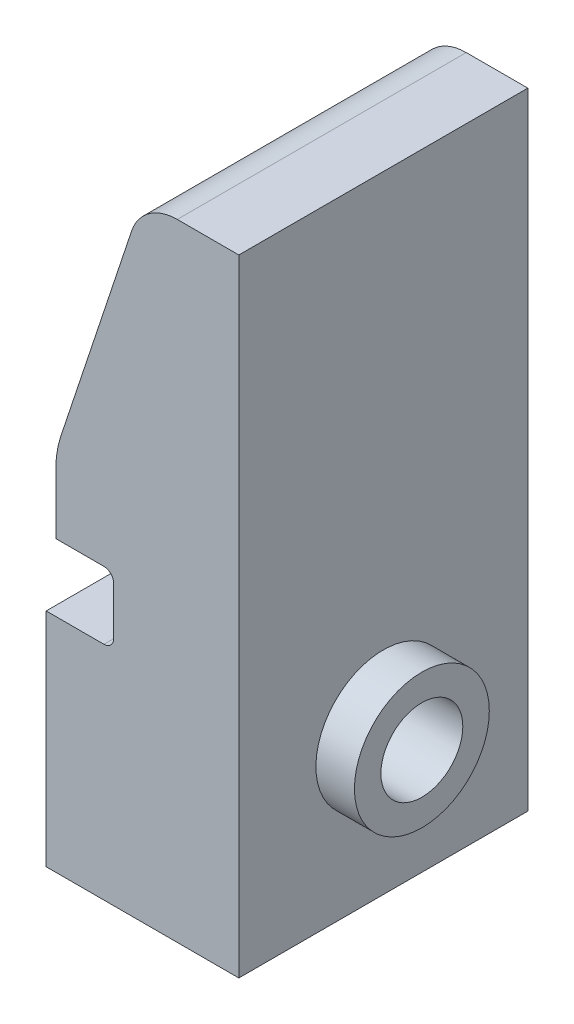
from build123d import *

# Parameters (mm, degrees)
EXTRUDE_1_DEPTH     = 30
SKETCH_2_R          = 4.25
CUT_EXTRUDE_1_DEPTH = 30
FILLET_1_R          = 10
FILLET_2_R          = 5
SKETCH_5_W          = 7
SKETCH_5_H          = 7
CUT_EXTRUDE_2_DEPTH = 20
FILLET_5_R          = 1
SKETCH_6_R          = 7
SKETCH_6_R_2        = 4.25
EXTRUDE_2_DEPTH     = 4


with BuildPart() as part:
    # 草图1 → 凸台-拉伸1 (new body)
    with BuildSketch(Plane.XY):
        Polygon((-4.331983806, 33.724696356), (-13.331983806, 6.619433198), (-13.331983806, -1.275303644), (-14.331983806, -1.275303644), (-14.331983806, -31.275303644), (5.668016194, -31.275303644), (5.668016194, 33.724696356), align=None)
    extrude(amount=EXTRUDE_1_DEPTH)

    # 草图2 → 切除-拉伸1 (cut)
    with BuildSketch(Plane.ZY.offset(14.331983806)):
        with Locations(Location((15, -16.275303644, 0), (0, 0, 270))):
            Circle(SKETCH_2_R)
    extrude(amount=-CUT_EXTRUDE_1_DEPTH, mode=Mode.SUBTRACT)

    # 圆角1
    fillet_1_edges = [part.edges().sort_by_distance(p)[0] for p in [
        (-13.331983806, 6.619433198, 15),
    ]]
    fillet(fillet_1_edges, radius=FILLET_1_R)

    # 圆角2
    fillet_2_edges = [part.edges().sort_by_distance(p)[0] for p in [
        (-4.331983806, 33.724696356, 15),
    ]]
    fillet(fillet_2_edges, radius=FILLET_2_R)

    # 草图5 → 切除-拉伸2 (cut)
    with BuildSketch(Plane.XY.offset(30)):
        with Locations((-10.831983806, -4.775303644)):
            Rectangle(SKETCH_5_W, SKETCH_5_H)
    extrude(amount=-CUT_EXTRUDE_2_DEPTH, mode=Mode.SUBTRACT)

    # 圆角5
    fillet_5_edges = [part.edges().sort_by_distance(p)[0] for p in [
        (-10.331983806, -1.275303644, 10),
        (-7.331983806, -4.775303644, 10),
        (-7.331983806, -1.275303644, 20),
        (-10.831983806, -8.275303644, 10),
        (-7.331983806, -8.275303644, 20),
    ]]
    fillet(fillet_5_edges, radius=FILLET_5_R)

    # 草图6 → 凸台-拉伸2 (add)
    with BuildSketch(Plane(origin=(5.668016194, 0, 0), x_dir=(0, 0, -1), z_dir=(1, 0, 0))):
        with Locations(Location((-15, -16.275303644, 0), (0, 0, 270))):
            Circle(SKETCH_6_R)
        with Locations(Location((-15, -16.275303644, 0), (0, 0, 270))):
            Circle(SKETCH_6_R_2, mode=Mode.SUBTRACT)
    extrude(amount=EXTRUDE_2_DEPTH)


solid = part.part
